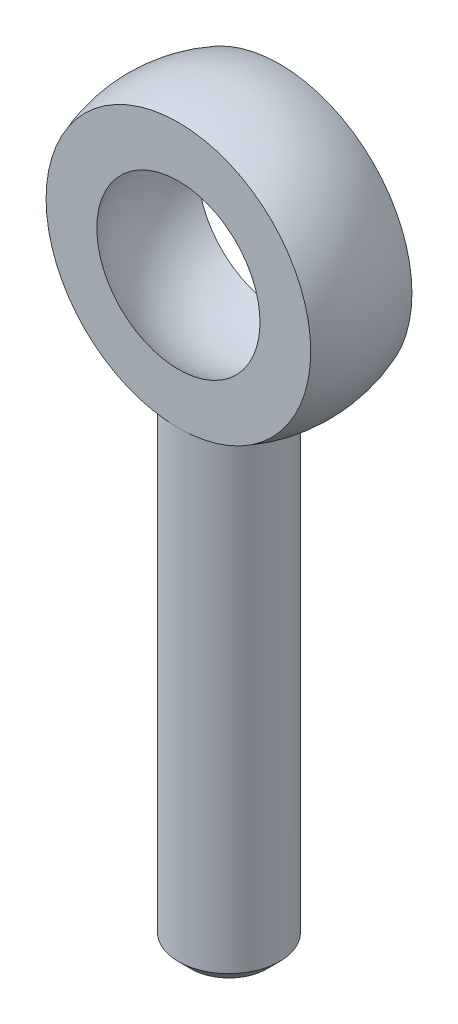
from build123d import *
from build123d.topology import SkipClean

# Parameters (mm, degrees)
SKETCH5_R           = 3.96875
EXTRUDE2_DEPTH      = 3
EXTRUDE2_DEPTH_BACK = 36.52
CHAMFER1_SIZE       = 1


with BuildPart() as part:
    # Sketch3 → Revolve2 (revolve)
    with BuildSketch(Plane(origin=(0, 0, 0), x_dir=(0, 0, -1), z_dir=(1, 0, 0))):
        with BuildLine():
            Line((-3.96875, 10.379628109), (-3.96875, 0))
            Line((-3.96875, 0), (3.96875, 0))
            Line((3.96875, 0), (3.96875, 10.379628109))
            ThreePointArc((3.96875, 10.379628109), (0, 11.1125), (-3.96875, 10.379628109))
        make_face()
    revolve(axis=Axis((0, 0, 8.146649187), (0, 0, -1)))

    # Sketch2 → Cut-Revolve2 (revolve, cut)
    with BuildSketch(Plane(origin=(0, 0, 0), x_dir=(0, 0, -1), z_dir=(1, 0, 0))):
        with BuildLine():
            Line((0, 7.5311), (0, -7.5311))
            ThreePointArc((0, -7.5311), (7.5311, 0), (0, 7.5311))
        make_face()
    revolve(axis=Axis((0, 15.474361319, 0), (0, -1, 0)), mode=Mode.SUBTRACT)

    # Sketch5 → Extrude2 (add, two sides)
    with SkipClean():  # the faces are left unmerged after this step: merging them gives an invalid solid
        with BuildSketch(Plane(origin=(0, -11.1125, 0), x_dir=(-1, 0, 0), z_dir=(0, 1, 0))) as extrude2_sk:
            with Locations(Location((0, 0, 0), (0, 0, 90))):
                Circle(SKETCH5_R)
        extrude(amount=EXTRUDE2_DEPTH)
        extrude(extrude2_sk.sketch, amount=-EXTRUDE2_DEPTH_BACK)

    # Chamfer1
    chamfer1_edges = [part.edges().sort_by_distance(p)[0] for p in [
        (0, -47.6325, -3.96875),
    ]]
    chamfer(chamfer1_edges, length=CHAMFER1_SIZE)


solid = part.part
